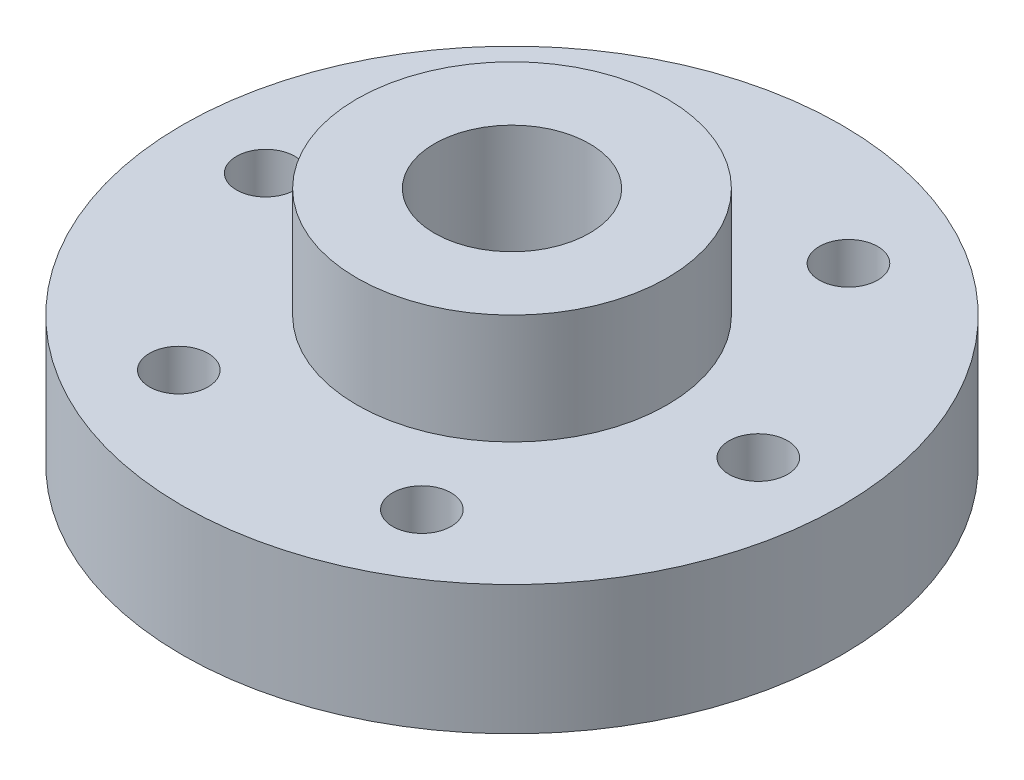
from build123d import *

# Parameters (mm, degrees)
SKETCH1_R             = 12.75
BOSS_EXTRUDE1_DEPTH   = 5
SKETCH2_R             = 6
BOSS_EXTRUDE2_DEPTH   = 4.25
SKETCH3_R             = 3
CUT_EXTRUDE1_DEPTH    = 10.25
F_4_40_TAPPED_HOLE2_D = 2.2606


with BuildPart() as part:
    # Sketch1 → Boss-Extrude1 (new body)
    with BuildSketch(Plane(origin=(0, 0, 0), x_dir=(1, 0, 0), z_dir=(0, 1, 0))):
        Circle(SKETCH1_R)
    extrude(amount=BOSS_EXTRUDE1_DEPTH)

    # Sketch2 → Boss-Extrude2 (add)
    with BuildSketch(Plane(origin=(0, 5, 0), x_dir=(1, 0, 0), z_dir=(0, 1, 0))):
        Circle(SKETCH2_R)
    extrude(amount=BOSS_EXTRUDE2_DEPTH)

    # Sketch3 → Cut-Extrude1 (cut, through all)
    with BuildSketch(Plane(origin=(0, 9.25, 0), x_dir=(1, 0, 0), z_dir=(0, 1, 0))):
        Circle(SKETCH3_R)
    extrude(amount=-CUT_EXTRUDE1_DEPTH, mode=Mode.SUBTRACT)

    # #4-40 Tapped Hole2 (through all)
    with Locations(Plane(origin=(0, 5, 0), x_dir=(1, 0, 0), z_dir=(0, 1, 0))):
        with Locations((-4.609677481, -8.277058611), (-9.525, 0), (4.7625, -8.248891971), (9.525, 0), (-4.7625, 8.248891971), (4.7625, 8.248891971)):
            Hole(F_4_40_TAPPED_HOLE2_D / 2)


solid = part.part
